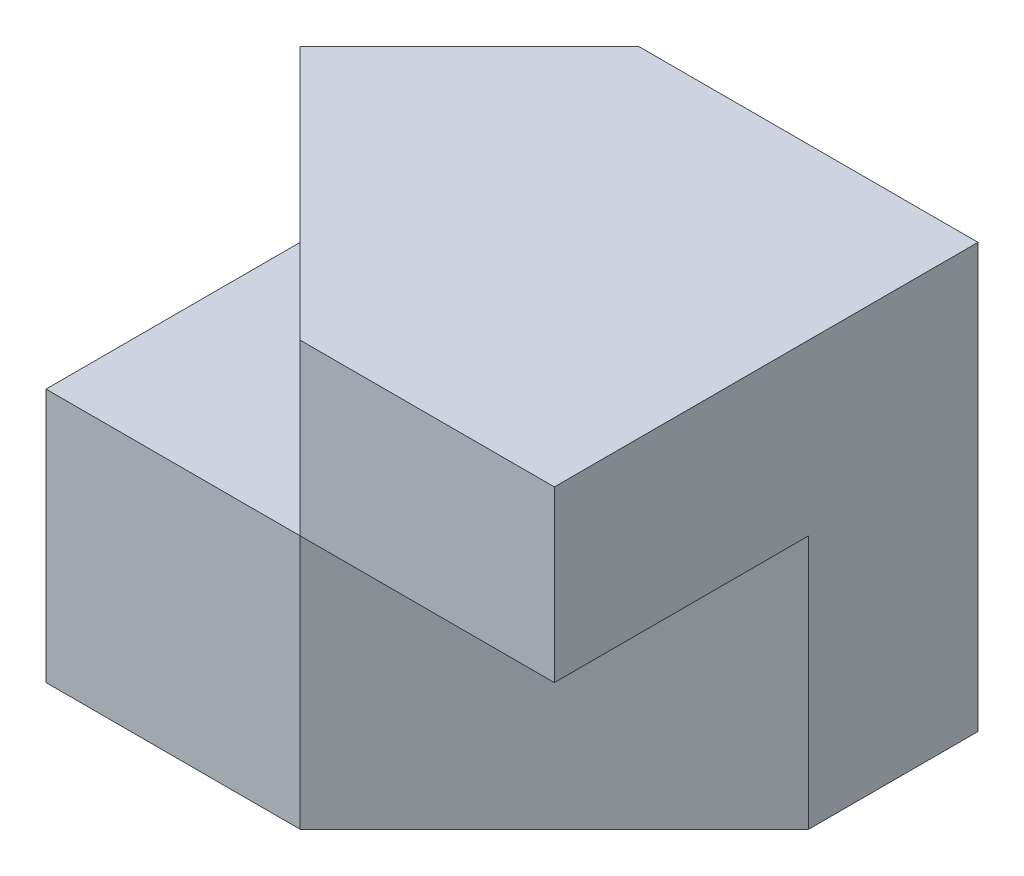
from build123d import *

# Parameters (mm, degrees)
SKETCH1_W           = 6
SKETCH1_H           = 5
BOSS_EXTRUDE1_DEPTH = 5
CUT_EXTRUDE1_DEPTH  = 5
CUT_EXTRUDE2_DEPTH  = 2
CUT_EXTRUDE3_DEPTH  = 3


with BuildPart() as part:
    # Sketch1 → Boss-Extrude1 (new body)
    with BuildSketch(Plane.XY):
        with Locations((3, 2.5)):
            Rectangle(SKETCH1_W, SKETCH1_H)
    extrude(amount=BOSS_EXTRUDE1_DEPTH)

    # Sketch4 → Cut-Extrude1 (cut)
    with BuildSketch(Plane(origin=(0, 5, 0), x_dir=(1, 0, 0), z_dir=(0, 1, 0))):
        Polygon((0, -2), (2, 0), (0, 0), align=None)
    extrude(amount=-CUT_EXTRUDE1_DEPTH, mode=Mode.SUBTRACT)

    # Sketch5 → Cut-Extrude2 (cut)
    with BuildSketch(Plane(origin=(0, 5, 0), x_dir=(1, 0, 0), z_dir=(0, 1, 0))):
        Polygon((0, -2), (3, -5), (0, -5), align=None)
    extrude(amount=-CUT_EXTRUDE2_DEPTH, mode=Mode.SUBTRACT)

    # Sketch6 → Cut-Extrude3 (cut)
    with BuildSketch(Plane.XZ):
        Polygon((6, 5), (3, 5), (6, 2), align=None)
    extrude(amount=-CUT_EXTRUDE3_DEPTH, mode=Mode.SUBTRACT)


solid = part.part
